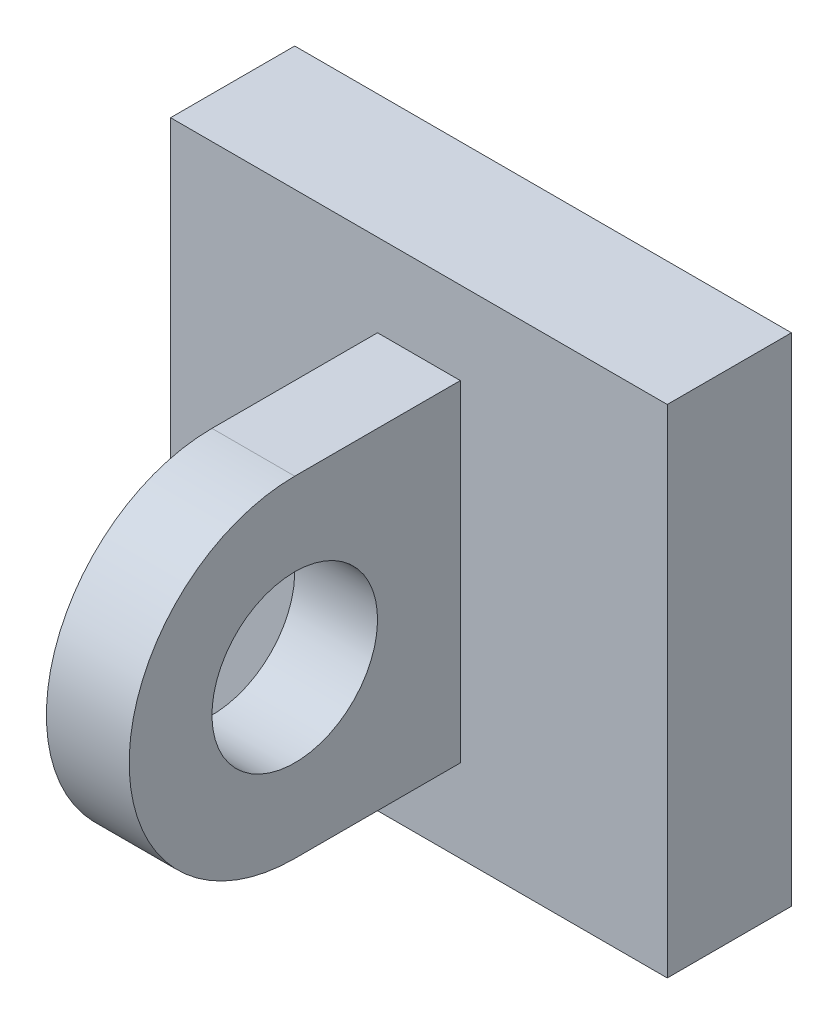
from build123d import *

# Parameters (mm, degrees)
SKETCH1_W           = 60
SKETCH1_H           = 60
BOSS_EXTRUDE1_DEPTH = 7.5
SKETCH3_R           = 10
BOSS_EXTRUDE2_DEPTH = 5


with BuildPart() as part:
    # Sketch1 → Boss-Extrude1 (new body, symmetric)
    with BuildSketch(Plane.XY):
        Rectangle(SKETCH1_W, SKETCH1_H)
    extrude(amount=BOSS_EXTRUDE1_DEPTH, both=True)

    # Sketch3 → Boss-Extrude2 (add, symmetric)
    with BuildSketch(Plane(origin=(0, 0, 0), x_dir=(0, 0, -1), z_dir=(1, 0, 0))):
        with BuildLine():
            Line((-7.5, 20), (-27.5, 20))
            ThreePointArc((-27.5, 20), (-47.5, 0), (-27.5, -20))
            Line((-27.5, -20), (-7.5, -20))
            Line((-7.5, -20), (-7.5, 20))
        make_face()
        with Locations((-27.5, 0)):
            Circle(SKETCH3_R, mode=Mode.SUBTRACT)
    extrude(amount=BOSS_EXTRUDE2_DEPTH, both=True)


solid = part.part
